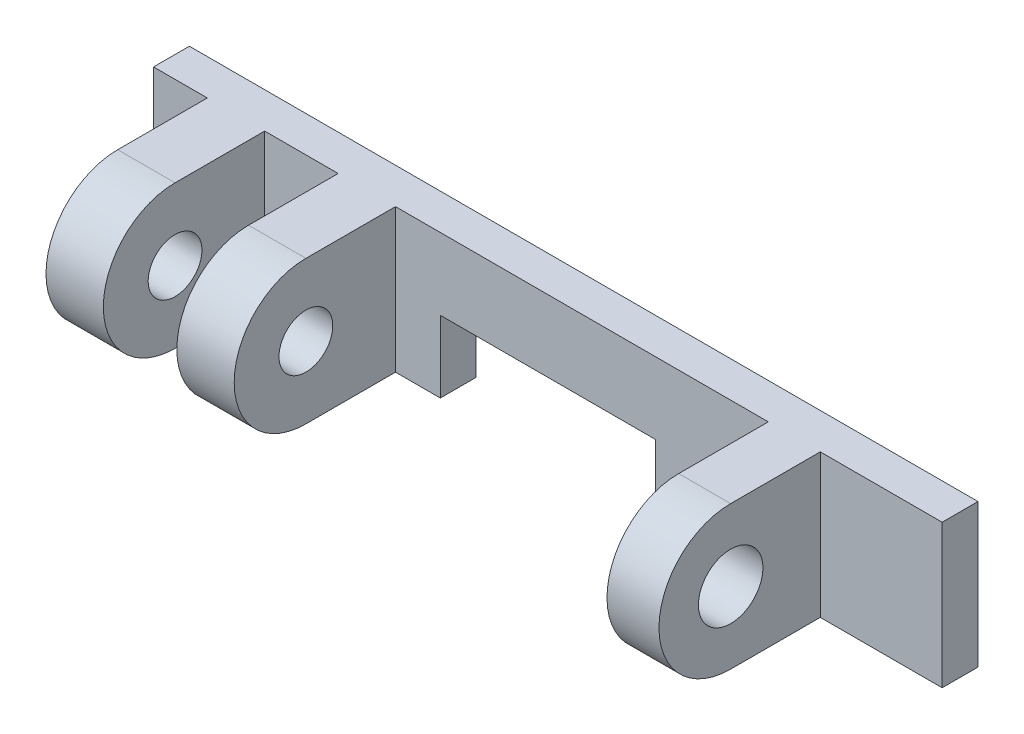
from build123d import *

# Parameters (mm, degrees)
BOSS_EXTRUDE1_START = -9.5
SKETCH1_R           = 0.75
BOSS_EXTRUDE1_DEPTH = 1.6
BOSS_EXTRUDE2_START = -5.85
SKETCH1_3_R         = 0.75
BOSS_EXTRUDE2_DEPTH = 1.6
BOSS_EXTRUDE5_START = 7.6
SKETCH1_5_R         = 2
SKETCH1_5_R_2       = 0.9
BOSS_EXTRUDE5_DEPTH = 1.45
BOSS_EXTRUDE3_START = 11
SKETCH1_4_W         = 1
SKETCH1_4_H         = 4
BOSS_EXTRUDE3_DEPTH = 22
CUT_EXTRUDE1_START  = 3
SKETCH1_6_W         = 1
SKETCH1_6_H         = 2
CUT_EXTRUDE1_DEPTH  = 6


with BuildPart() as part:
    # Sketch1 → Boss-Extrude1 (new body)
    with BuildSketch(Plane(origin=(0, 0, 0), x_dir=(0, 0, -1), z_dir=(1, 0, 0)).offset(BOSS_EXTRUDE1_START)):
        with BuildLine():
            Line((2.5, 2), (0, 2))
            ThreePointArc((0, 2), (-2, 0), (0, -2))
            Line((0, -2), (2.5, -2))
            Line((2.5, -2), (2.5, 2))
        make_face()
        with Locations(Location((0, 0, 0), (0, 0, 180))):
            Circle(SKETCH1_R, mode=Mode.SUBTRACT)
    extrude(amount=BOSS_EXTRUDE1_DEPTH)



with BuildPart() as body_2:
    # Sketch1_3 → Boss-Extrude2 (new body)
    with BuildSketch(Plane(origin=(0, 0, 0), x_dir=(0, 0, -1), z_dir=(1, 0, 0)).offset(BOSS_EXTRUDE2_START)):
        with BuildLine():
            Line((2.5, 2), (0, 2))
            ThreePointArc((0, 2), (-2, 0), (0, -2))
            Line((0, -2), (2.5, -2))
            Line((2.5, -2), (2.5, 2))
        make_face()
        with Locations(Location((0, 0, 0), (0, 0, 180))):
            Circle(SKETCH1_3_R, mode=Mode.SUBTRACT)
    extrude(amount=BOSS_EXTRUDE2_DEPTH)


with BuildPart() as body_3:
    # Sketch1_5 → Boss-Extrude5 (new body)
    with BuildSketch(Plane(origin=(0, 0, 0), x_dir=(0, 0, -1), z_dir=(1, 0, 0)).offset(BOSS_EXTRUDE5_START)):
        Circle(SKETCH1_5_R)
        Circle(SKETCH1_5_R_2, mode=Mode.SUBTRACT)
        with BuildLine():
            Line((2.5, 2), (0, 2))
            ThreePointArc((0, 2), (1.414213562, 1.414213562), (2, 0))
            ThreePointArc((2, 0), (1.414213562, -1.414213562), (0, -2))
            Line((0, -2), (2.5, -2))
            Line((2.5, -2), (2.5, 0))
            Line((2.5, 0), (2.5, 2))
        make_face()
    extrude(amount=-BOSS_EXTRUDE5_DEPTH)


with BuildPart() as part_1:
    add(part.part)

    add(body_2.part)  # Boss-Extrude3 merges body 2

    add(body_3.part)  # Boss-Extrude3 merges body 3
    # Sketch1_4 → Boss-Extrude3 (add)
    with BuildSketch(Plane(origin=(0, 0, 0), x_dir=(0, 0, -1), z_dir=(1, 0, 0)).offset(BOSS_EXTRUDE3_START)):
        with Locations((3, 0)):
            Rectangle(SKETCH1_4_W, SKETCH1_4_H)
    extrude(amount=-BOSS_EXTRUDE3_DEPTH)

    # Sketch1_6 → Cut-Extrude1 (cut)
    with BuildSketch(Plane(origin=(0, 0, 0), x_dir=(0, 0, -1), z_dir=(1, 0, 0)).offset(CUT_EXTRUDE1_START)):
        with Locations((3, -1)):
            Rectangle(SKETCH1_6_W, SKETCH1_6_H)
    extrude(amount=-CUT_EXTRUDE1_DEPTH, mode=Mode.SUBTRACT)


solid = part_1.part
